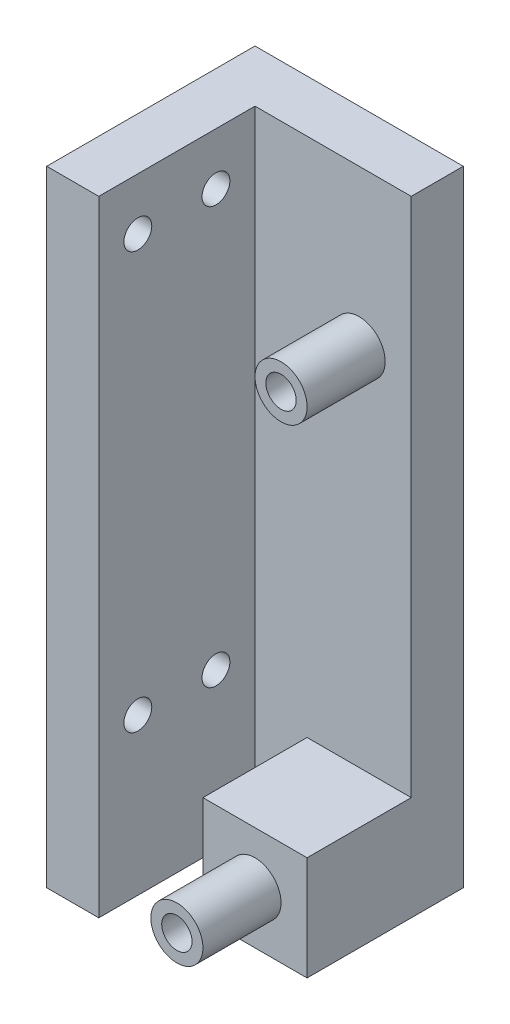
from build123d import *

# Parameters (mm, degrees)
SKETCH1_W           = 25.4
SKETCH1_H           = 76.2
BOSS_EXTRUDE1_DEPTH = 25.4
SKETCH10_W          = 19.05
SKETCH10_H          = 76.2
CUT_EXTRUDE5_DEPTH  = 19.05
BOSS_EXTRUDE2_START = -6.35
SKETCH12_R          = 3.175
SKETCH12_R_2        = 1.849999983
BOSS_EXTRUDE2_DEPTH = 9.525
BOSS_EXTRUDE3_START = -6.35
SKETCH13_W          = 12.7
SKETCH13_H          = 12.7
BOSS_EXTRUDE3_DEPTH = 12.7
SKETCH14_R          = 3.175
SKETCH14_R_2        = 1.849999983
BOSS_EXTRUDE4_DEPTH = 9.525
SKETCH15_R          = 1.700000029
CUT_EXTRUDE6_DEPTH  = 7.35


with BuildPart() as part:
    # Sketch1 → Boss-Extrude1 (new body)
    with BuildSketch(Plane.XY):
        with Locations((12.7, 38.1)):
            Rectangle(SKETCH1_W, SKETCH1_H)
    extrude(amount=-BOSS_EXTRUDE1_DEPTH)

    # Sketch10 → Cut-Extrude5 (cut)
    with BuildSketch(Plane(origin=(25.4, 0, 0), x_dir=(0, 0, -1), z_dir=(1, 0, 0))):
        with Locations((9.525, 38.1)):
            Rectangle(SKETCH10_W, SKETCH10_H)
    extrude(amount=-CUT_EXTRUDE5_DEPTH, mode=Mode.SUBTRACT)

    # Sketch12 → Boss-Extrude2 (add)
    with BuildSketch(Plane(origin=(0, 0, -25.4), x_dir=(-1, 0, 0), z_dir=(0, 0, -1)).offset(BOSS_EXTRUDE2_START)):
        with Locations((-19.05, 57.15)):
            Circle(SKETCH12_R)
        with Locations((-19.05, 57.15)):
            Circle(SKETCH12_R_2, mode=Mode.SUBTRACT)
    extrude(amount=-BOSS_EXTRUDE2_DEPTH)

    # Sketch13 → Boss-Extrude3 (add)
    with BuildSketch(Plane(origin=(0, 0, -25.4), x_dir=(-1, 0, 0), z_dir=(0, 0, -1)).offset(BOSS_EXTRUDE3_START)):
        with Locations((-19.05, 6.35)):
            Rectangle(SKETCH13_W, SKETCH13_H)
    extrude(amount=-BOSS_EXTRUDE3_DEPTH)

    # Sketch14 → Boss-Extrude4 (add)
    with BuildSketch(Plane.XY.offset(-6.35)):
        with Locations((19.05, 6.35)):
            Circle(SKETCH14_R)
        with Locations((19.05, 6.35)):
            Circle(SKETCH14_R_2, mode=Mode.SUBTRACT)
    extrude(amount=BOSS_EXTRUDE4_DEPTH)

    # Sketch15 → Cut-Extrude6 (cut, through all)
    with BuildSketch(Plane(origin=(6.35, 0, 0), x_dir=(0, 0, -1), z_dir=(1, 0, 0))):
        with Locations((4.7625, 69.85)):
            Circle(SKETCH15_R)
        with Locations((14.2875, 69.85)):
            Circle(SKETCH15_R)
        with Locations((4.7625, 19.05)):
            Circle(SKETCH15_R)
        with Locations((14.2875, 19.05)):
            Circle(SKETCH15_R)
    extrude(amount=-CUT_EXTRUDE6_DEPTH, mode=Mode.SUBTRACT)


solid = part.part
